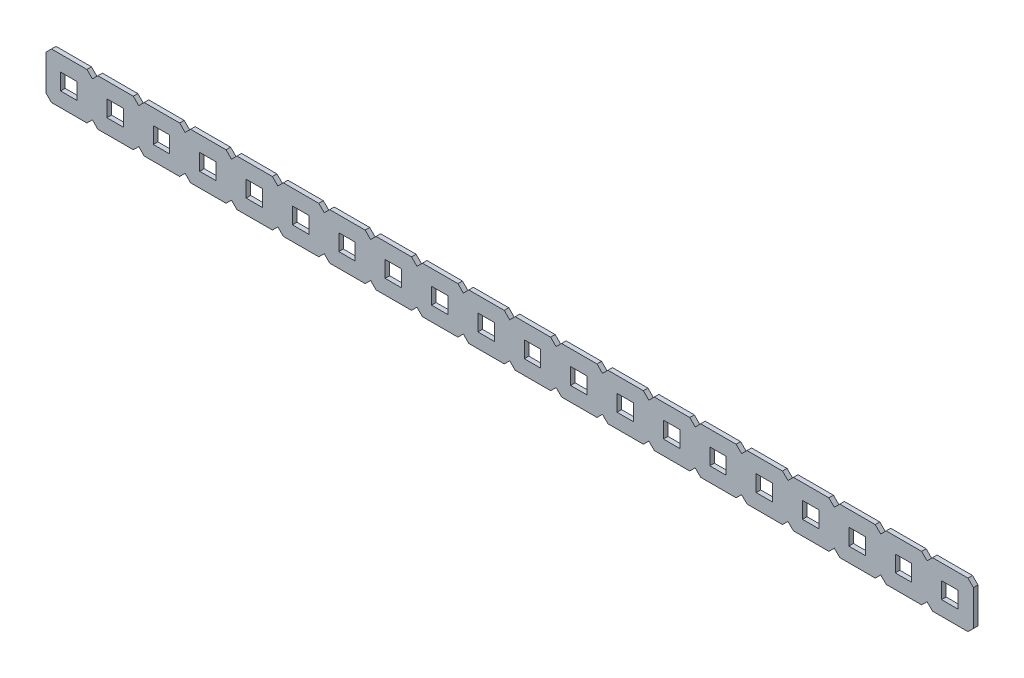
from build123d import *

# Parameters (mm, degrees)
SKETCH1_W           = 319
SKETCH1_H           = 12.75
BOSS_EXTRUDE1_DEPTH = 1.25
SKETCH2_W           = 4.5
SKETCH2_H           = 4.5
CUT_EXTRUDE1_DEPTH  = 18.25
SKETCH3_W           = 4.5
SKETCH3_H           = 4.5
CUT_EXTRUDE2_DEPTH  = 18.25
CUT_EXTRUDE3_DEPTH  = 18.25


with BuildPart() as part:
    # Sketch1 → Boss-Extrude1 (new body)
    with BuildSketch(Plane.XY):
        with Locations((159.5, 6.375)):
            Rectangle(SKETCH1_W, SKETCH1_H)
    extrude(amount=BOSS_EXTRUDE1_DEPTH)

    # Sketch2 → Cut-Extrude1 (cut)
    with BuildSketch(Plane.XY.offset(1.25)):
        with Locations((6.25, 6.25)):
            Rectangle(SKETCH2_W, SKETCH2_H)
        with Locations((19, 6.25)):
            Rectangle(SKETCH2_W, SKETCH2_H)
        with Locations((31.75, 6.25)):
            Rectangle(SKETCH2_W, SKETCH2_H)
        with Locations((44.5, 6.25)):
            Rectangle(SKETCH2_W, SKETCH2_H)
        with Locations((57.25, 6.25)):
            Rectangle(SKETCH2_W, SKETCH2_H)
        with Locations((70, 6.25)):
            Rectangle(SKETCH2_W, SKETCH2_H)
        with Locations((82.75, 6.25)):
            Rectangle(SKETCH2_W, SKETCH2_H)
        with Locations((95.5, 6.25)):
            Rectangle(SKETCH2_W, SKETCH2_H)
        with Locations((108.25, 6.25)):
            Rectangle(SKETCH2_W, SKETCH2_H)
        with Locations((133.75, 6.25)):
            Rectangle(SKETCH2_W, SKETCH2_H)
        with Locations((146.5, 6.25)):
            Rectangle(SKETCH2_W, SKETCH2_H)
        with Locations((172, 6.25)):
            Rectangle(SKETCH2_W, SKETCH2_H)
        with Locations((184.75, 6.25)):
            Rectangle(SKETCH2_W, SKETCH2_H)
        with Locations((210.25, 6.25)):
            Rectangle(SKETCH2_W, SKETCH2_H)
        with Locations((223, 6.25)):
            Rectangle(SKETCH2_W, SKETCH2_H)
        with Locations((235.75, 6.25)):
            Rectangle(SKETCH2_W, SKETCH2_H)
        with Locations((248.5, 6.25)):
            Rectangle(SKETCH2_W, SKETCH2_H)
        with Locations((261.25, 6.25)):
            Rectangle(SKETCH2_W, SKETCH2_H)
        with Locations((274, 6.25)):
            Rectangle(SKETCH2_W, SKETCH2_H)
        with Locations((286.75, 6.25)):
            Rectangle(SKETCH2_W, SKETCH2_H)
        with Locations((299.5, 6.25)):
            Rectangle(SKETCH2_W, SKETCH2_H)
        with Locations((312.25, 6.25)):
            Rectangle(SKETCH2_W, SKETCH2_H)
        Polygon((0, 12.75), (0, 11.25), (1.5, 12.75), align=None)
        Polygon((1.5, 0), (0, 1.5), (0, 0), align=None)
        Polygon((14.25, 12.75), (11.25, 12.75), (12.75, 11.25), align=None)
        Polygon((12.75, 1.5), (11.25, 0), (14.25, 0), align=None)
        Polygon((25.5, 1.5), (24, 0), (27, 0), align=None)
        Polygon((27, 12.75), (24, 12.75), (25.5, 11.25), align=None)
        Polygon((38.25, 1.5), (36.75, 0), (39.75, 0), align=None)
        Polygon((52.5, 12.75), (49.5, 12.75), (51, 11.25), align=None)
        Polygon((51, 1.5), (49.5, 0), (52.5, 0), align=None)
        Polygon((39.75, 12.75), (36.75, 12.75), (38.25, 11.25), align=None)
        Polygon((65.25, 12.75), (62.25, 12.75), (63.75, 11.25), align=None)
        Polygon((63.75, 1.5), (62.25, 0), (65.25, 0), align=None)
        Polygon((76.5, 1.5), (75, 0), (78, 0), align=None)
        Polygon((78, 12.75), (75, 12.75), (76.5, 11.25), align=None)
        Polygon((90.75, 12.75), (87.75, 12.75), (89.25, 11.25), align=None)
        Polygon((89.25, 1.5), (87.75, 0), (90.75, 0), align=None)
        Polygon((102, 1.5), (100.5, 0), (103.5, 0), align=None)
        Polygon((103.5, 12.75), (100.5, 12.75), (102, 11.25), align=None)
        Polygon((116.25, 12.75), (113.25, 12.75), (114.75, 11.25), align=None)
        Polygon((114.75, 1.5), (113.25, 0), (116.25, 0), align=None)
        Polygon((127.5, 1.5), (126, 0), (129, 0), align=None)
        Polygon((129, 12.75), (126, 12.75), (127.5, 11.25), align=None)
        Polygon((140.25, 1.5), (138.75, 0), (141.75, 0), align=None)
        Polygon((141.75, 12.75), (138.75, 12.75), (140.25, 11.25), align=None)
        Polygon((154.5, 12.75), (151.5, 12.75), (153, 11.25), align=None)
        Polygon((153, 1.5), (151.5, 0), (154.5, 0), align=None)
        Polygon((167.25, 12.75), (164.25, 12.75), (165.75, 11.25), align=None)
        Polygon((180, 12.75), (177, 12.75), (178.5, 11.25), align=None)
        Polygon((192.75, 12.75), (189.75, 12.75), (191.25, 11.25), align=None)
        Polygon((205.5, 12.75), (202.5, 12.75), (204, 11.25), align=None)
        Polygon((218.25, 12.75), (215.25, 12.75), (216.75, 11.25), align=None)
        Polygon((231, 12.75), (228, 12.75), (229.5, 11.25), align=None)
        Polygon((243.75, 12.75), (240.75, 12.75), (242.25, 11.25), align=None)
        Polygon((256.5, 12.75), (253.5, 12.75), (255, 11.25), align=None)
        Polygon((269.25, 12.75), (266.25, 12.75), (267.75, 11.25), align=None)
        Polygon((282, 12.75), (279, 12.75), (280.5, 11.25), align=None)
        Polygon((294.75, 12.75), (291.75, 12.75), (293.25, 11.25), align=None)
        Polygon((307.5, 12.75), (304.5, 12.75), (306, 11.25), align=None)
        Polygon((318.75, 1.5), (317.25, 0), (319, 0), (319, 12.75), (317.25, 12.75), (318.75, 11.25), align=None)
        Polygon((306, 1.5), (304.5, 0), (307.5, 0), align=None)
        Polygon((293.25, 1.5), (291.75, 0), (294.75, 0), align=None)
        Polygon((280.5, 1.5), (279, 0), (282, 0), align=None)
        Polygon((267.75, 1.5), (266.25, 0), (269.25, 0), align=None)
        Polygon((255, 1.5), (253.5, 0), (256.5, 0), align=None)
        Polygon((242.25, 1.5), (240.75, 0), (243.75, 0), align=None)
        Polygon((229.5, 1.5), (228, 0), (231, 0), align=None)
        Polygon((165.75, 1.5), (164.25, 0), (167.25, 0), align=None)
        Polygon((178.5, 1.5), (177, 0), (180, 0), align=None)
        Polygon((191.25, 1.5), (189.75, 0), (192.75, 0), align=None)
        Polygon((204, 1.5), (202.5, 0), (205.5, 0), align=None)
        Polygon((216.75, 1.5), (215.25, 0), (218.25, 0), align=None)
        with Locations((121, 6.25)):
            Rectangle(SKETCH2_W, SKETCH2_H)
        with Locations((197.5, 6.25)):
            Rectangle(SKETCH2_W, SKETCH2_H)
    extrude(amount=-CUT_EXTRUDE1_DEPTH, mode=Mode.SUBTRACT)

    # Sketch3 → Cut-Extrude2 (cut)
    with BuildSketch(Plane.XY.offset(1.25)):
        with Locations((159.25, 6.25)):
            Rectangle(SKETCH3_W, SKETCH3_H)
        with Locations((146.5, 6.25)):
            Rectangle(SKETCH3_W, SKETCH3_H)
    extrude(amount=-CUT_EXTRUDE2_DEPTH, mode=Mode.SUBTRACT)

    # Sketch4 → Cut-Extrude3 (cut)
    with BuildSketch(Plane.XY.offset(1.25)):
        Polygon((255, 14.329492595), (255, 11.25), (255, 1.5), (255, -2.349525885), (322.855665697, -2.349525885), (322.855665697, 14.329492595), align=None)
    extrude(amount=-CUT_EXTRUDE3_DEPTH, mode=Mode.SUBTRACT)


solid = part.part
